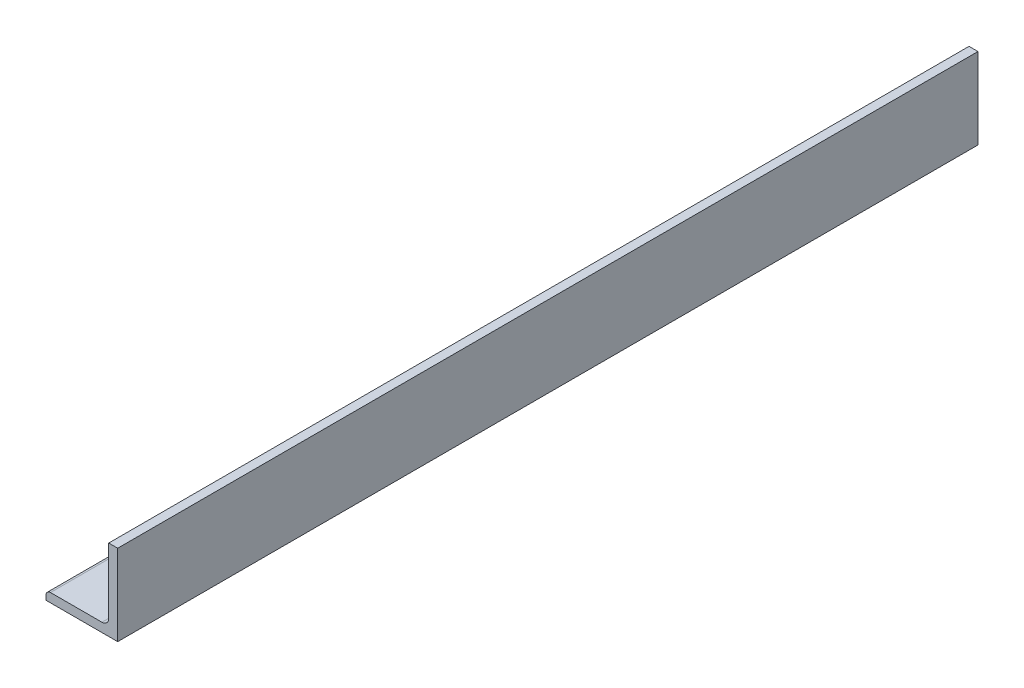
from build123d import *

# Parameters (mm, degrees)
BOSS_EXTRUDE1_DEPTH = 304.8
SKETCH3_W           = 30.020943331
SKETCH3_H           = 21.596699029
CUT_EXTRUDE1_DEPTH  = 612.317372565


with BuildPart() as part:
    # Sketch2 → Boss-Extrude1 (new, symmetric)
    with BuildSketch(Plane.XY):
        with BuildLine():
            Line((-25.4, -38.1), (25.4, -38.1))
            Line((25.4, -38.1), (25.4, 38.1))
            Line((25.4, 38.1), (22.225, 38.1))
            ThreePointArc((22.225, 38.1), (19.97993597, 37.17006403), (19.05, 34.925))
            Line((19.05, 34.925), (19.05, -26.9748))
            ThreePointArc((19.05, -26.9748), (17.651376302, -30.351376302), (14.2748, -31.75))
            Line((14.2748, -31.75), (-22.225, -31.75))
            ThreePointArc((-22.225, -31.75), (-24.47006403, -32.67993597), (-25.4, -34.925))
            Line((-25.4, -34.925), (-25.4, -38.1))
        make_face()
    extrude(amount=BOSS_EXTRUDE1_DEPTH, both=True)

    # Sketch3 → Cut-Extrude1 (cut, through all)
    with BuildSketch(Plane.XY.offset(304.8)):
        with Locations((23.779344144, 30.05923535)):
            Rectangle(SKETCH3_W, SKETCH3_H)
    extrude(amount=-CUT_EXTRUDE1_DEPTH, mode=Mode.SUBTRACT)


solid = part.part
